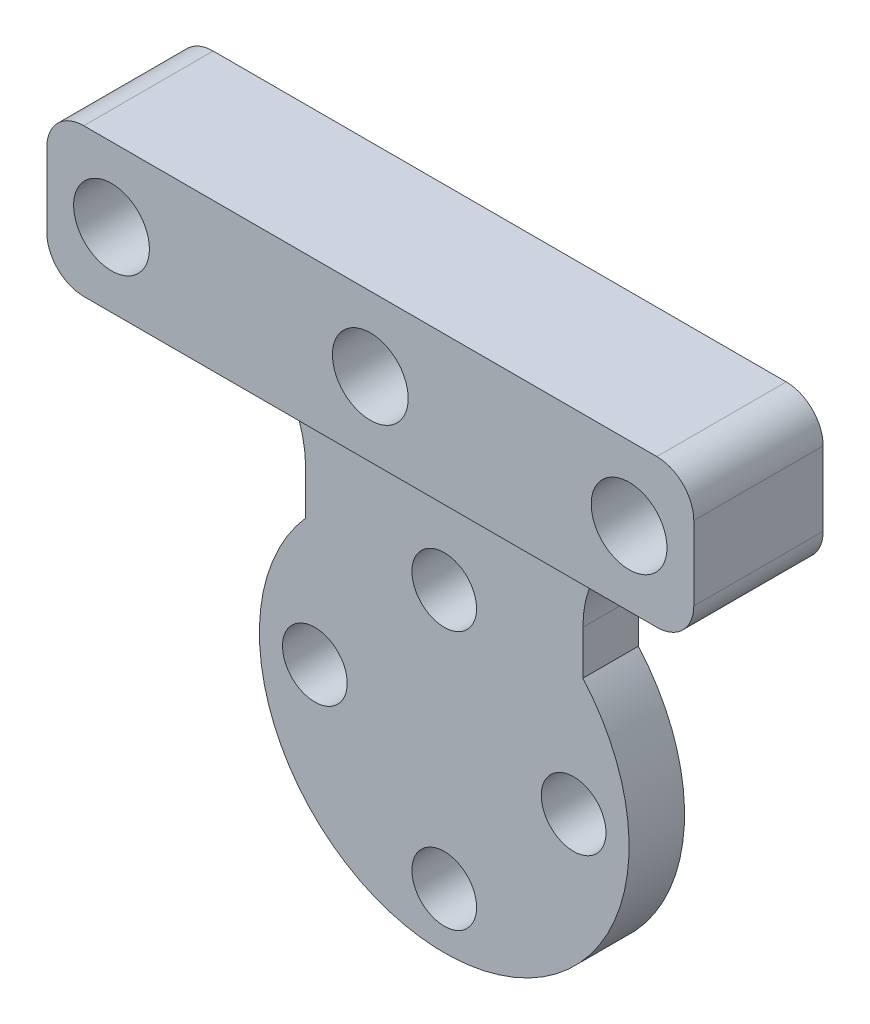
from build123d import *

# Parameters (mm, degrees)
SKETCH_1_R          = 10
SKETCH_1_R_2        = 1.75
EXTRUDE_1_DEPTH     = 3
EXTRUDE_2_DEPTH     = 3
SKETCH_7_W          = 35
SKETCH_7_H          = 8
EXTRUDE_3_DEPTH     = 4
FILLET_1_R          = 6
SKETCH_8_R          = 1.75
CUT_EXTRUDE_2_DEPTH = 8
FILLET_2_R          = 2
SKETCH_10_R         = 2.05
CUT_EXTRUDE_3_DEPTH = 6


with BuildPart() as part:
    # Эскиз1 → Бобышка-Вытянуть1 (new body)
    with BuildSketch(Plane.XY):
        Circle(SKETCH_1_R)
        with Locations((-7, 0)):
            Circle(SKETCH_1_R_2, mode=Mode.SUBTRACT)
        with Locations((0, 7)):
            Circle(SKETCH_1_R_2, mode=Mode.SUBTRACT)
        with Locations((7, 0)):
            Circle(SKETCH_1_R_2, mode=Mode.SUBTRACT)
        with Locations((0, -7)):
            Circle(SKETCH_1_R_2, mode=Mode.SUBTRACT)
    extrude(amount=EXTRUDE_1_DEPTH)

    # Эскиз6 → Бобышка-Вытянуть2 (add)
    with BuildSketch(Plane.XY.offset(3)):
        with BuildLine():
            Line((-7.5, 15), (-7.5, 6.614378278))
            ThreePointArc((-7.5, 6.614378278), (0, 10), (7.5, 6.614378278))
            Line((7.5, 6.614378278), (7.5, 15))
            Line((7.5, 15), (17.5, 15))
            Line((17.5, 15), (17.5, 23))
            Line((17.5, 23), (-17.5, 23))
            Line((-17.5, 23), (-17.5, 15))
            Line((-17.5, 15), (-7.5, 15))
        make_face()
    extrude(amount=-EXTRUDE_2_DEPTH)

    # Эскиз7 → Бобышка-Вытянуть3 (add)
    with BuildSketch(Plane.XY.offset(3)):
        with Locations((0, 19)):
            Rectangle(SKETCH_7_W, SKETCH_7_H)
    extrude(amount=EXTRUDE_3_DEPTH)

    # Скругление1
    fillet_1_edges = [part.edges().sort_by_distance(p)[0] for p in [
        (-7.5, 15, 1.5),
        (7.5, 15, 1.5),
    ]]
    fillet(fillet_1_edges, radius=FILLET_1_R)

    # Эскиз8 → Вырез-Вытянуть2 (cut, through all)
    with BuildSketch(Plane.XY.offset(7)):
        with Locations((0, 19)):
            Circle(SKETCH_8_R)
        with Locations((-14, 19)):
            Circle(SKETCH_8_R)
        with Locations((14, 19)):
            Circle(SKETCH_8_R)
    extrude(amount=-CUT_EXTRUDE_2_DEPTH, mode=Mode.SUBTRACT)

    # Скругление2
    fillet_2_edges = [part.edges().sort_by_distance(p)[0] for p in [
        (-17.5, 15, 3.5),
        (-17.5, 23, 3.5),
        (17.5, 23, 3.5),
        (17.5, 15, 3.5),
    ]]
    fillet(fillet_2_edges, radius=FILLET_2_R)

    # Эскиз10 → Вырез-Вытянуть3 (cut)
    with BuildSketch(Plane.XY.offset(7)):
        with Locations((-14, 19)):
            Circle(SKETCH_10_R)
        with Locations((0, 19)):
            Circle(SKETCH_10_R)
        with Locations((14, 19)):
            Circle(SKETCH_10_R)
    extrude(amount=-CUT_EXTRUDE_3_DEPTH, mode=Mode.SUBTRACT)


solid = part.part
